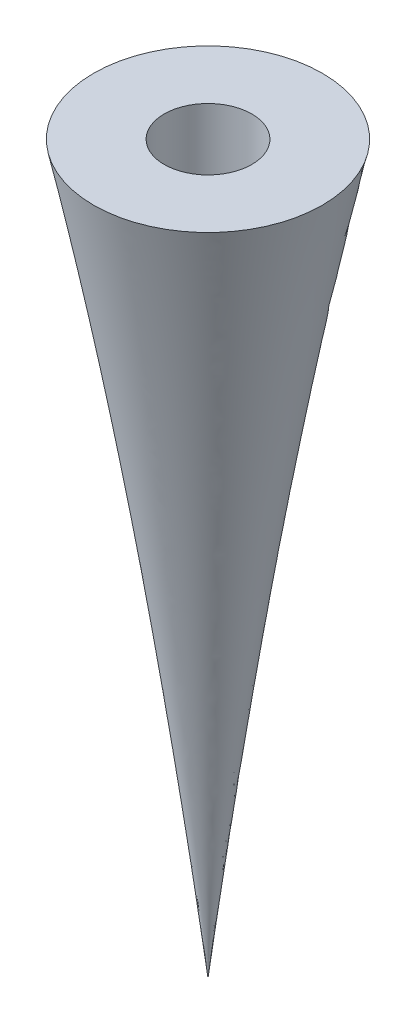
from build123d import *


with BuildPart() as part:
    # Sketch2 → Revolve1 (revolve)
    with BuildSketch(Plane(origin=(0, 0, 0), x_dir=(0, 0, -1), z_dir=(1, 0, 0))):
        with BuildLine():
            Line((-1.5875, -27.156781806), (-1.5875, -22.5))
            Line((-1.5875, -22.5), (-4.143040834, -22.5))
            add(Edge.make_bspline(
                [(-4.143040834, -22.5), (-4.125564027, -22.580819709), (-3.996621605, -23.179373348), (-3.754513457, -24.335495191), (-3.41952793, -26.012858361), (-3.075517026, -27.820552879), (-2.722684182, -29.77142225), (-2.360531816, -31.879838305), (-1.988974677, -34.162162662), (-1.607715514, -36.636974892), (-1.21675626, -39.325480295), (-0.815801597, -42.252016358), (-0.403306983, -45.444415751), (-0.138325749, -47.666056858), (0, -48.8258)],
                knots=[0.496098755, 0.496098755, 0.496098755, 0.496098755, 0.500787452, 0.530817523, 0.563076364, 0.597777275, 0.635158941, 0.675491346, 0.719081885, 0.766277675, 0.817476573, 0.873132108, 0.933772306, 1, 1, 1, 1], degree=3))
            Line((0, -48.8258), (0, -27.156781806))
            Line((0, -27.156781806), (-1.5875, -27.156781806))
        make_face()
    revolve(axis=Axis((0, -48.8258, 0), (0, 1, 0)))


solid = part.part
